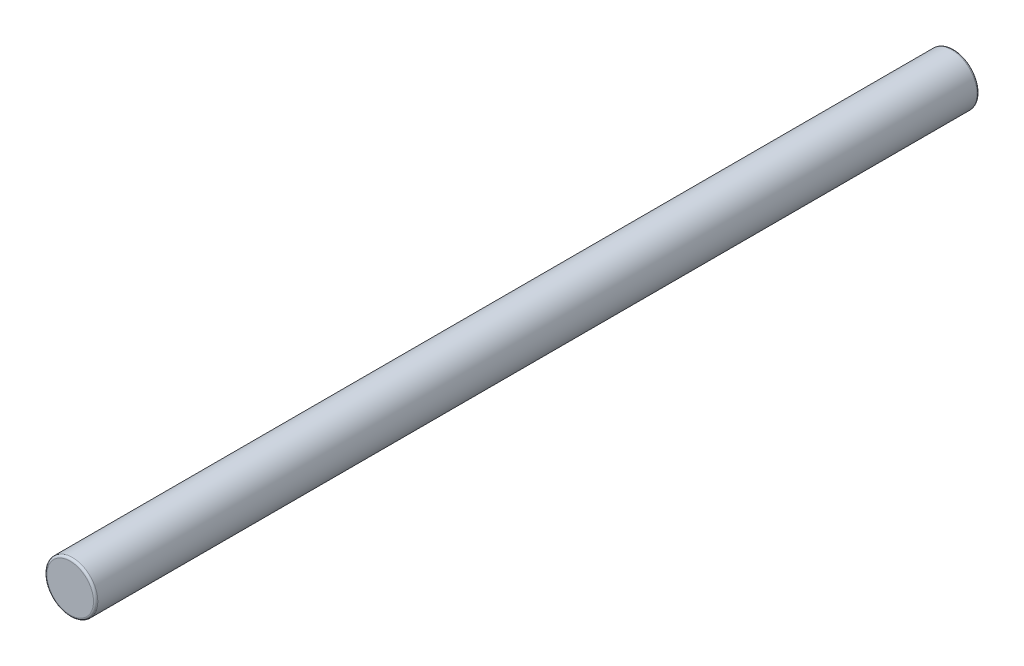
from build123d import *

# Parameters (mm, degrees)
SKETCH1_R           = 1.5
BOSS_EXTRUDE1_DEPTH = 26
FILLET1_R           = 0.127


with BuildPart() as part:
    # Sketch1 → Boss-Extrude1 (new body, symmetric)
    with BuildSketch(Plane.XY):
        Circle(SKETCH1_R)
    extrude(amount=BOSS_EXTRUDE1_DEPTH, both=True)

    # Fillet1
    fillet1_edges = [part.edges().sort_by_distance(p)[0] for p in [
        (-1.5, 0, -26),
        (-1.5, 0, 26),
    ]]
    fillet(fillet1_edges, radius=FILLET1_R)


solid = part.part
